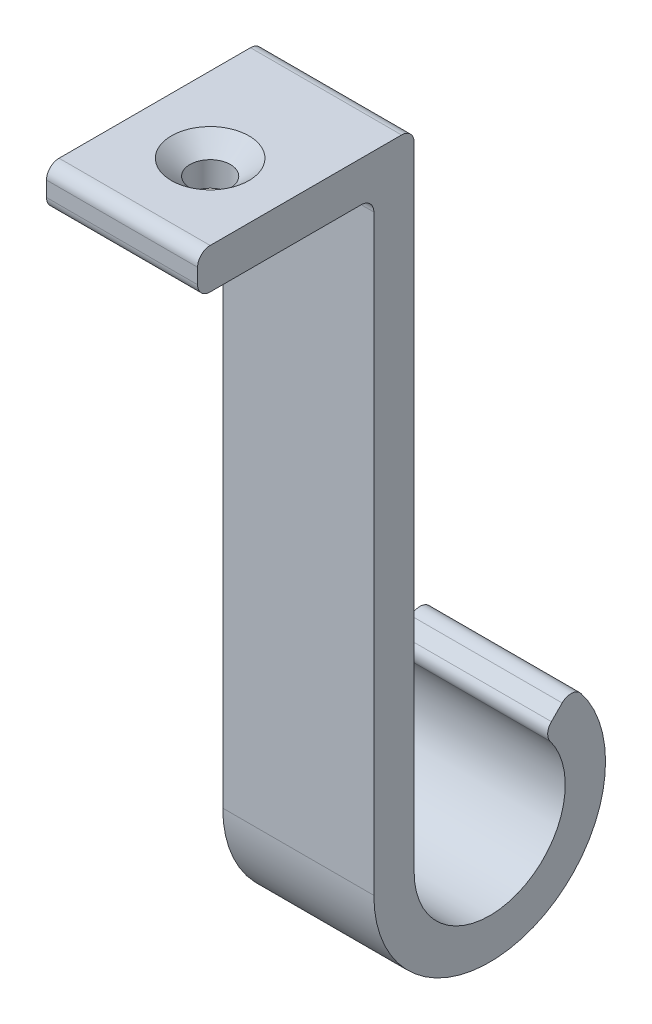
from build123d import *

# Parameters (mm, degrees)
BOSS_EXTRUDE1_DEPTH                                = 9.525
FILLET1_R                                          = 1.5875
CSK_FOR_10_FLAT_HEAD_MACHINE_SCREW_100_D           = 5.1054
CSK_FOR_10_FLAT_HEAD_MACHINE_SCREW_100_CSINK_D     = 9.779
CSK_FOR_10_FLAT_HEAD_MACHINE_SCREW_100_CSINK_ANGLE = 100


with BuildPart() as part:
    # Sketch1 → Boss-Extrude1 (new body, symmetric)
    with BuildSketch(Plane(origin=(0, 0, 0), x_dir=(0, 0, -1), z_dir=(1, 0, 0))):
        with BuildLine():
            Line((-13.6525, -2.54), (8.5725, -2.54))
            Line((8.5725, -2.54), (8.5725, -78.74))
            ThreePointArc((8.5725, -78.74), (28.76659153, -92.233260572), (33.504794539, -68.412705461))
            Line((33.504794539, -68.412705461), (29.912692091, -72.004807909))
            ThreePointArc((29.912692091, -72.004807909), (26.822559693, -87.539952547), (13.6525, -78.74))
            Line((13.6525, -78.74), (13.6525, 2.54))
            Line((13.6525, 2.54), (-13.6525, 2.54))
            Line((-13.6525, 2.54), (-13.6525, -2.54))
        make_face()
    extrude(amount=BOSS_EXTRUDE1_DEPTH, both=True)

    # Fillet1
    fillet1_edges = [part.edges().sort_by_distance(p)[0] for p in [
        (0, -72.004807909, -29.912692091),
        (0, -68.412705461, -33.504794539),
        (0, -2.54, -8.5725),
        (0, -2.54, 13.6525),
        (0, 2.54, 13.6525),
        (0, 2.54, -13.6525),
    ]]
    fillet(fillet1_edges, radius=FILLET1_R)

    # CSK for #10 Flat Head Machine Screw (100)1 (through all)
    with Locations(Plane(origin=(0, 2.54, 2.54), x_dir=(0, 0, 1), z_dir=(0, 1, 0))):
        with Locations((0, 0)):
            CounterSinkHole(CSK_FOR_10_FLAT_HEAD_MACHINE_SCREW_100_D / 2, CSK_FOR_10_FLAT_HEAD_MACHINE_SCREW_100_CSINK_D / 2, counter_sink_angle=CSK_FOR_10_FLAT_HEAD_MACHINE_SCREW_100_CSINK_ANGLE)


solid = part.part
